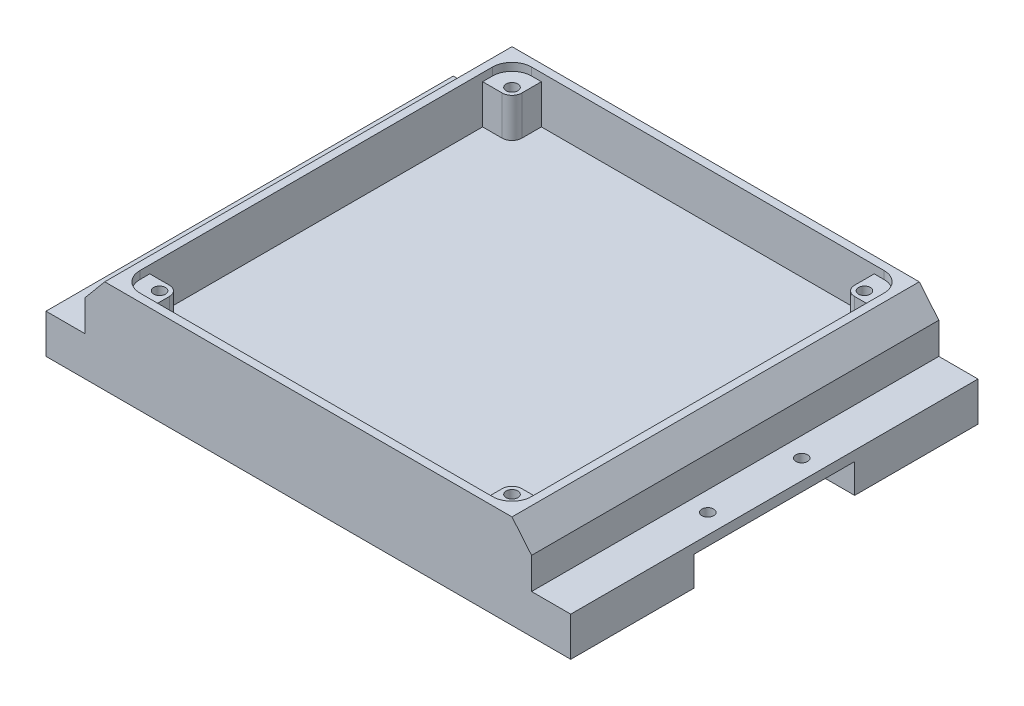
from build123d import *

# Parameters (mm, degrees)
BOSS_EXTRUDE3_DEPTH  = 12
BOSS_EXTRUDE5_DEPTH  = 12
BOSS_EXTRUDE6_DEPTH  = 12
BOSS_EXTRUDE7_DEPTH  = 12
SKETCH13_W           = 102
SKETCH13_H           = 12
BOSS_EXTRUDE11_DEPTH = 1
SKETCH14_W           = 103
SKETCH14_H           = 12
BOSS_EXTRUDE12_DEPTH = 1
SKETCH15_W           = 103
SKETCH15_H           = 12
BOSS_EXTRUDE13_DEPTH = 1
SKETCH16_W           = 104
SKETCH16_H           = 12
BOSS_EXTRUDE14_DEPTH = 1
SKETCH17_W           = 104
SKETCH17_H           = 104
BOSS_EXTRUDE16_DEPTH = 12
SKETCH20_W           = 104
SKETCH20_H           = 24
BOSS_EXTRUDE20_DEPTH = 10
CUT_EXTRUDE2_DEPTH   = 104
SKETCH23_W           = 104
SKETCH23_H           = 24
BOSS_EXTRUDE21_DEPTH = 10
CUT_EXTRUDE3_DEPTH   = 104
SKETCH26_W           = 10.4
SKETCH26_H           = 41.4
SKETCH26_W_2         = 10
SKETCH26_H_2         = 41
CUT_EXTRUDE5_DEPTH   = 7.5
SKETCH29_W           = 5
SKETCH29_H           = 104
CUT_EXTRUDE6_DEPTH   = 8
SKETCH30_W           = 5
SKETCH30_H           = 104
CUT_EXTRUDE7_DEPTH   = 8
BOSS_EXTRUDE22_DEPTH = 5
SKETCH33_W           = 41.4
SKETCH33_H           = 7.5
BOSS_EXTRUDE23_DEPTH = 5
BOSS_EXTRUDE24_DEPTH = 5
SKETCH35_W           = 41
SKETCH35_H           = 7.5
BOSS_EXTRUDE25_DEPTH = 5
SKETCH36_R           = 1.5
CUT_EXTRUDE8_DEPTH   = 2.5
SKETCH37_R           = 1.5
CUT_EXTRUDE9_DEPTH   = 2.5
SKETCH38_R           = 2.5
SKETCH38_R_2         = 1.5
BOSS_EXTRUDE26_DEPTH = 10


with BuildPart() as part:
    # Sketch1 → Boss-Extrude3 (new body)
    with BuildSketch(Plane(origin=(0, 0, 0), x_dir=(1, 0, 0), z_dir=(0, 1, 0))):
        with BuildLine():
            Line((-46, 51), (46, 51))
            ThreePointArc((46, 51), (49.535533906, 49.535533906), (51, 46))
            Line((51, 46), (51, -46))
            ThreePointArc((51, -46), (49.535533906, -49.535533906), (46, -51))
            Line((46, -51), (-46, -51))
            ThreePointArc((-46, -51), (-49.535533906, -49.535533906), (-51, -46))
            Line((-51, -46), (-51, 46))
            ThreePointArc((-51, 46), (-49.535533906, 49.535533906), (-46, 51))
        make_face()
    extrude(amount=BOSS_EXTRUDE3_DEPTH)

    # Sketch4 → Boss-Extrude5 (add)
    with BuildSketch(Plane(origin=(0, 0, 0), x_dir=(-1, 0, 0), z_dir=(0, -1, 0))):
        with BuildLine():
            Line((-46, -51), (-51, -51))
            Line((-51, -51), (-51, -46))
            ThreePointArc((-51, -46), (-49.535533906, -49.535533906), (-46, -51))
        make_face()
    extrude(amount=-BOSS_EXTRUDE5_DEPTH)

    # Sketch6 → Boss-Extrude6 (add)
    with BuildSketch(Plane.XZ):
        with BuildLine():
            Line((-51, -46), (-51, -51))
            Line((-51, -51), (-46, -51))
            ThreePointArc((-46, -51), (-49.535533906, -49.535533906), (-51, -46))
        make_face()
    extrude(amount=-BOSS_EXTRUDE6_DEPTH)

    # Sketch7 → Boss-Extrude7 (add)
    with BuildSketch(Plane.XZ):
        with BuildLine():
            Line((-46, 51), (-51, 51))
            Line((-51, 51), (-51, 46))
            ThreePointArc((-51, 46), (-49.535533906, 49.535533906), (-46, 51))
        make_face()
        with BuildLine():
            Line((46, -51), (51, -51))
            Line((51, -51), (51, -46))
            ThreePointArc((51, -46), (49.535533906, -49.535533906), (46, -51))
        make_face()
    extrude(amount=-BOSS_EXTRUDE7_DEPTH)

    # Sketch13 → Boss-Extrude11 (add)
    with BuildSketch(Plane.XY.offset(51)):
        with Locations((0, 6)):
            Rectangle(SKETCH13_W, SKETCH13_H)
    extrude(amount=BOSS_EXTRUDE11_DEPTH)

    # Sketch14 → Boss-Extrude12 (add)
    with BuildSketch(Plane(origin=(51, 0, 0), x_dir=(0, 0, -1), z_dir=(1, 0, 0))):
        with Locations((-0.5, 6)):
            Rectangle(SKETCH14_W, SKETCH14_H)
    extrude(amount=BOSS_EXTRUDE12_DEPTH)

    # Sketch15 → Boss-Extrude13 (add)
    with BuildSketch(Plane(origin=(0, 0, -51), x_dir=(-1, 0, 0), z_dir=(0, 0, -1))):
        with Locations((-0.5, 6)):
            Rectangle(SKETCH15_W, SKETCH15_H)
    extrude(amount=BOSS_EXTRUDE13_DEPTH)

    # Sketch16 → Boss-Extrude14 (add)
    with BuildSketch(Plane.ZY.offset(51)):
        with Locations((0, 6)):
            Rectangle(SKETCH16_W, SKETCH16_H)
    extrude(amount=BOSS_EXTRUDE14_DEPTH)

    # Sketch17 → Boss-Extrude16 (add)
    with BuildSketch(Plane(origin=(0, 12, 0), x_dir=(1, 0, 0), z_dir=(0, 1, 0))):
        Rectangle(SKETCH17_W, SKETCH17_H)
        with BuildLine():
            Line((-45, 50), (45, 50))
            ThreePointArc((45, 50), (48.535533906, 48.535533906), (50, 45))
            Line((50, 45), (50, -45))
            ThreePointArc((50, -45), (48.535533906, -48.535533906), (45, -50))
            Line((45, -50), (-45, -50))
            ThreePointArc((-45, -50), (-48.535533906, -48.535533906), (-50, -45))
            Line((-50, -45), (-50, 45))
            ThreePointArc((-50, 45), (-48.535533906, 48.535533906), (-45, 50))
        make_face(mode=Mode.SUBTRACT)
    extrude(amount=BOSS_EXTRUDE16_DEPTH)

    # Sketch20 → Boss-Extrude20 (add)
    with BuildSketch(Plane(origin=(52, 0, 0), x_dir=(0, 0, -1), z_dir=(1, 0, 0))):
        with Locations((0, 12)):
            Rectangle(SKETCH20_W, SKETCH20_H)
    extrude(amount=BOSS_EXTRUDE20_DEPTH)

    # Sketch21 → Cut-Extrude2 (cut)
    with BuildSketch(Plane.XY.offset(52)):
        Polygon((62, 24), (52, 24), (57, 18), (62, 18), align=None)
    extrude(amount=-CUT_EXTRUDE2_DEPTH, mode=Mode.SUBTRACT)

    # Sketch23 → Boss-Extrude21 (add)
    with BuildSketch(Plane.ZY.offset(52)):
        with Locations((0, 12)):
            Rectangle(SKETCH23_W, SKETCH23_H)
    extrude(amount=BOSS_EXTRUDE21_DEPTH)

    # Sketch24 → Cut-Extrude3 (cut)
    with BuildSketch(Plane.XY.offset(52)):
        Polygon((-62, 24), (-52, 24), (-57, 18), (-62, 18), align=None)
    extrude(amount=-CUT_EXTRUDE3_DEPTH, mode=Mode.SUBTRACT)

    # Sketch26 → Cut-Extrude5 (cut)
    with BuildSketch(Plane.XZ):
        with Locations((-56.8, 0)):
            Rectangle(SKETCH26_W, SKETCH26_H)
        with Locations((57, 0)):
            Rectangle(SKETCH26_W_2, SKETCH26_H_2)
    extrude(amount=-CUT_EXTRUDE5_DEPTH, mode=Mode.SUBTRACT)

    # Sketch29 → Cut-Extrude6 (cut)
    with BuildSketch(Plane(origin=(0, 18, 0), x_dir=(1, 0, 0), z_dir=(0, 1, 0))):
        with Locations((59.5, 0)):
            Rectangle(SKETCH29_W, SKETCH29_H)
    extrude(amount=-CUT_EXTRUDE6_DEPTH, mode=Mode.SUBTRACT)

    # Sketch30 → Cut-Extrude7 (cut)
    with BuildSketch(Plane(origin=(0, 18, 0), x_dir=(1, 0, 0), z_dir=(0, 1, 0))):
        with Locations((-59.5, 0)):
            Rectangle(SKETCH30_W, SKETCH30_H)
    extrude(amount=-CUT_EXTRUDE7_DEPTH, mode=Mode.SUBTRACT)

    # Sketch32 → Boss-Extrude22 (add)
    with BuildSketch(Plane.ZY.offset(62)):
        Polygon((-52, 10), (-52, 0), (-20.7, 0), (-20.7, 7.5), (20.7, 7.5), (20.7, 0), (52, 0), (52, 10), align=None)
    extrude(amount=BOSS_EXTRUDE22_DEPTH)

    # Sketch33 → Boss-Extrude23 (add)
    with BuildSketch(Plane.ZY.offset(51.6)):
        with Locations((0, 3.75)):
            Rectangle(SKETCH33_W, SKETCH33_H)
    extrude(amount=BOSS_EXTRUDE23_DEPTH)

    # Sketch34 → Boss-Extrude24 (add)
    with BuildSketch(Plane(origin=(62, 0, 0), x_dir=(0, 0, -1), z_dir=(1, 0, 0))):
        Polygon((-52, 10), (-52, 0), (-20.5, 0), (-20.5, 7.5), (20.5, 7.5), (20.5, 0), (52, 0), (52, 10), align=None)
    extrude(amount=BOSS_EXTRUDE24_DEPTH)

    # Sketch35 → Boss-Extrude25 (add)
    with BuildSketch(Plane(origin=(52, 0, 0), x_dir=(0, 0, -1), z_dir=(1, 0, 0))):
        with Locations((0, 3.75)):
            Rectangle(SKETCH35_W, SKETCH35_H)
    extrude(amount=BOSS_EXTRUDE25_DEPTH)

    # Sketch36 → Cut-Extrude8 (cut)
    with BuildSketch(Plane.XZ.offset(-7.5)):
        with Locations((62, 12)):
            Circle(SKETCH36_R)
        with Locations((62, -12)):
            Circle(SKETCH36_R)
    extrude(amount=-CUT_EXTRUDE8_DEPTH, mode=Mode.SUBTRACT)

    # Sketch37 → Cut-Extrude9 (cut)
    with BuildSketch(Plane.XZ.offset(-7.5)):
        with Locations((-62, 12)):
            Circle(SKETCH37_R)
        with Locations((-62, -12)):
            Circle(SKETCH37_R)
    extrude(amount=-CUT_EXTRUDE9_DEPTH, mode=Mode.SUBTRACT)

    # Sketch38 → Boss-Extrude26 (add)
    with BuildSketch(Plane(origin=(0, 12, 0), x_dir=(1, 0, 0), z_dir=(0, 1, 0))):
        with BuildLine():
            Line((-42.5, 50), (-45, 50))
            ThreePointArc((-45, 50), (-48.535533906, 48.535533906), (-50, 45))
            Line((-50, 45), (-50, 42.5))
            Line((-50, 42.5), (-45, 42.5))
            ThreePointArc((-45, 42.5), (-46.767766953, 46.767766953), (-42.5, 45))
            Line((-42.5, 45), (-42.5, 50))
        make_face()
        with Locations((-45, 45)):
            Circle(SKETCH38_R)
        with Locations((-45, 45)):
            Circle(SKETCH38_R_2, mode=Mode.SUBTRACT)
        with BuildLine():
            Line((45, 50), (42.5, 50))
            Line((42.5, 50), (42.5, 45))
            ThreePointArc((42.5, 45), (45, 47.5), (47.5, 45))
            ThreePointArc((47.5, 45), (46.767766953, 43.232233047), (45, 42.5))
            Line((45, 42.5), (50, 42.5))
            Line((50, 42.5), (50, 45))
            ThreePointArc((50, 45), (48.535533906, 48.535533906), (45, 50))
        make_face()
        with Locations((45, 45)):
            Circle(SKETCH38_R)
        with Locations((45, 45)):
            Circle(SKETCH38_R_2, mode=Mode.SUBTRACT)
        with BuildLine():
            Line((-45, -42.5), (-50, -42.5))
            Line((-50, -42.5), (-50, -45))
            ThreePointArc((-50, -45), (-48.535533906, -48.535533906), (-45, -50))
            Line((-45, -50), (-42.5, -50))
            Line((-42.5, -50), (-42.5, -45))
            ThreePointArc((-42.5, -45), (-46.767766953, -46.767766953), (-45, -42.5))
        make_face()
        with Locations((-45, -45)):
            Circle(SKETCH38_R)
        with Locations((-45, -45)):
            Circle(SKETCH38_R_2, mode=Mode.SUBTRACT)
        with BuildLine():
            Line((50, -45), (50, -42.5))
            Line((50, -42.5), (45, -42.5))
            ThreePointArc((45, -42.5), (46.767766953, -43.232233047), (47.5, -45))
            ThreePointArc((47.5, -45), (45, -47.5), (42.5, -45))
            Line((42.5, -45), (42.5, -50))
            Line((42.5, -50), (45, -50))
            ThreePointArc((45, -50), (48.535533906, -48.535533906), (50, -45))
        make_face()
        with Locations((45, -45)):
            Circle(SKETCH38_R)
        with Locations((45, -45)):
            Circle(SKETCH38_R_2, mode=Mode.SUBTRACT)
    extrude(amount=BOSS_EXTRUDE26_DEPTH)


solid = part.part
